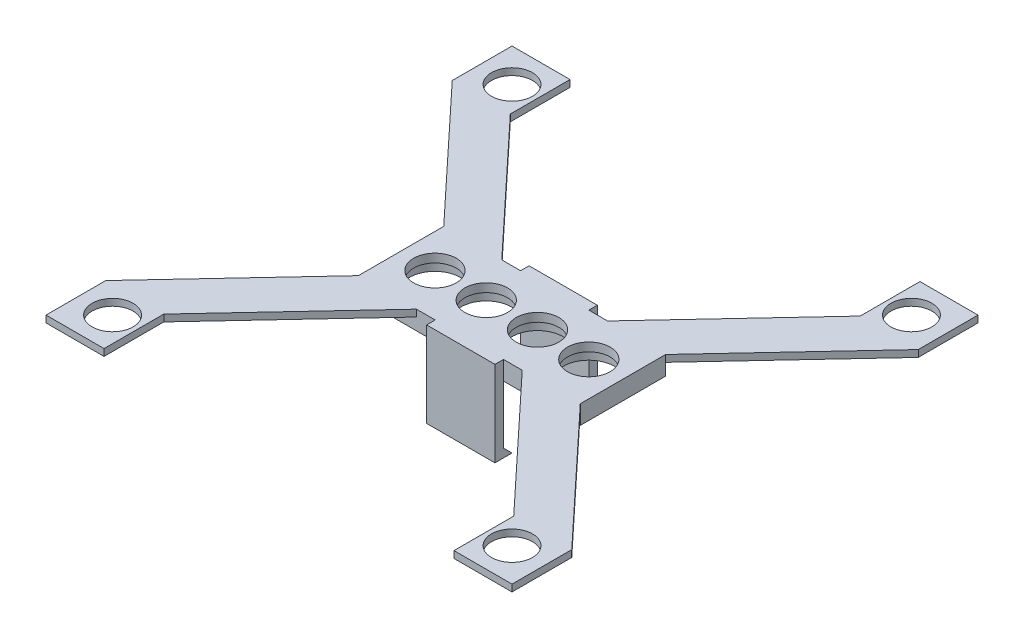
from build123d import *

# Parameters (mm, degrees)
SKICA1_W                 = 26
SKICA1_H                 = 1
P_IDAT_VYSUNUT_M1_DEPTH  = 10
SKICA2_R                 = 2.5
ODEBRAT_VYSUNUT_M1_DEPTH = 1
SKICA3_R                 = 2.4
P_IDAT_VYSUNUT_M2_DEPTH  = 0.8
SKICA4_W                 = 26
SKICA4_H                 = 10
SKICA4_R                 = 3
P_IDAT_VYSUNUT_M3_DEPTH  = 1.2
SKICA6_W                 = 8
SKICA6_H                 = 1
P_IDAT_VYSUNUT_M5_DEPTH  = 10
P_IDAT_VYSUNUT_M6_DEPTH  = 8


with BuildPart() as part:
    # Skica1 → Přidat vysunutím1 (new body)
    with BuildSketch(Plane.XY):
        with Locations((-39.156744291, -7.214704976)):
            Rectangle(SKICA1_W, SKICA1_H)
    extrude(amount=P_IDAT_VYSUNUT_M1_DEPTH)

    # Skica2 → Odebrat vysunutím1 (cut)
    with BuildSketch(Plane(origin=(0, -7.714704976, 0), x_dir=(-1, 0, 0), z_dir=(0, -1, 0))):
        with Locations((48.186744291, -5)):
            Circle(SKICA2_R)
        with Locations((42.176744291, -5)):
            Circle(SKICA2_R)
        with Locations((36.166744291, -5)):
            Circle(SKICA2_R)
        with Locations((30.156744291, -5)):
            Circle(SKICA2_R)
    extrude(amount=-ODEBRAT_VYSUNUT_M1_DEPTH, mode=Mode.SUBTRACT)

    # Skica3 → Přidat vysunutím2 (add)
    with BuildSketch(Plane(origin=(0, -6.714704976, 0), x_dir=(1, 0, 0), z_dir=(0, 1, 0))):
        Polygon((-32.956744291, 0), (-18.656744291, 15.3), (-18.656744291, 22.3), (-11.856744291, 22.3), (-11.856744291, 15.3), (-26.156744291, 0), align=None)
        with Locations((-15.756744291, 18.4)):
            Circle(SKICA3_R, mode=Mode.SUBTRACT)
        Polygon((-52.156744291, 0), (-45.356744291, 0), (-59.656744291, 15.3), (-59.656744291, 22.3), (-66.456744291, 22.3), (-66.456744291, 15.3), align=None)
        with Locations((-62.556744291, 18.4)):
            Circle(SKICA3_R, mode=Mode.SUBTRACT)
        Polygon((-45.356744291, -10), (-59.656744291, -25.3), (-59.656744291, -32.3), (-66.456744291, -32.3), (-66.456744291, -25.3), (-52.156744291, -10), align=None)
        with Locations((-62.556744291, -28.4)):
            Circle(SKICA3_R, mode=Mode.SUBTRACT)
        Polygon((-26.156744291, -10), (-32.956744291, -10), (-18.656744291, -25.3), (-18.656744291, -32.3), (-11.856744291, -32.3), (-11.856744291, -25.3), align=None)
        with Locations((-15.756744291, -28.4)):
            Circle(SKICA3_R, mode=Mode.SUBTRACT)
    extrude(amount=-P_IDAT_VYSUNUT_M2_DEPTH)

    # Skica4 → Přidat vysunutím3 (add)
    with BuildSketch(Plane(origin=(0, -7.714704976, 0), x_dir=(-1, 0, 0), z_dir=(0, -1, 0))):
        with Locations((39.156744291, -5)):
            Rectangle(SKICA4_W, SKICA4_H)
        with Locations((48.186744291, -5)):
            Circle(SKICA4_R, mode=Mode.SUBTRACT)
        with Locations((42.176744291, -5)):
            Circle(SKICA4_R, mode=Mode.SUBTRACT)
        with Locations((36.166744291, -5)):
            Circle(SKICA4_R, mode=Mode.SUBTRACT)
        with Locations((30.156744291, -5)):
            Circle(SKICA4_R, mode=Mode.SUBTRACT)
    extrude(amount=P_IDAT_VYSUNUT_M3_DEPTH)

    # Skica6 → Přidat vysunutím5 (add)
    with BuildSketch(Plane(origin=(0, -6.714704976, 0), x_dir=(1, 0, 0), z_dir=(0, 1, 0))):
        with Locations((-39.156744291, 0.5)):
            Rectangle(SKICA6_W, SKICA6_H)
        with Locations((-39.156744291, -10.5)):
            Rectangle(SKICA6_W, SKICA6_H)
    extrude(amount=-P_IDAT_VYSUNUT_M5_DEPTH)

    # Skica7 → Přidat vysunutím6 (add)
    with BuildSketch(Plane(origin=(-35.156744291, 0, 0), x_dir=(0, 0, -1), z_dir=(1, 0, 0))):
        Polygon((0, -16.714704976), (-1, -16.714704976), (0, -15.714704976), align=None)
        Polygon((-10, -16.714704976), (-9, -16.714704976), (-10, -15.714704976), align=None)
    extrude(amount=-P_IDAT_VYSUNUT_M6_DEPTH)


solid = part.part
